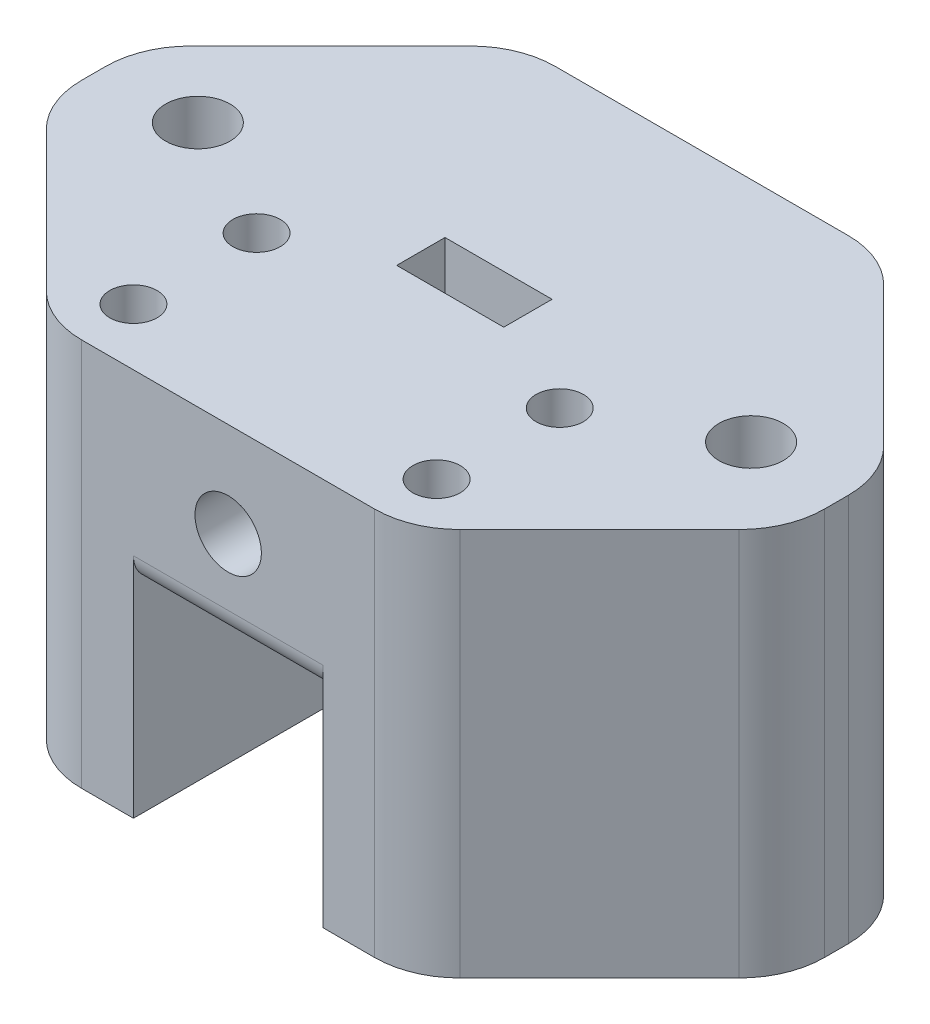
from build123d import *

# Parameters (mm, degrees)
SKETCH1_W                      = 39.2
SKETCH1_H                      = 25
BOSS_EXTRUDE1_DEPTH            = 10
F_3_5_3_5_DIAMETER_HOLE1_D     = 3.5
SKETCH9_W                      = 14.6
SKETCH9_H                      = 25
BOSS_EXTRUDE2_DEPTH            = 10.5
SKETCH10_W                     = 5.65
SKETCH10_H                     = 2.55
CUT_EXTRUDE4_DEPTH             = 10
F_2_5_2_5_DIAMETER_HOLE1_D     = 2.5
F_2_5_2_5_DIAMETER_HOLE1_DEPTH = 7
F_2_5_2_5_DIAMETER_HOLE1_TIP   = 0.751075774
F_3_4_3_4_DIAMETER_HOLE1_D     = 3.4
CHAMFER1_SIZE                  = 10
FILLET5_R                      = 4.5
FILLET6_R                      = 1.5
F_3_4_3_4_DIAMETER_HOLE2_D     = 3.4
F_3_4_3_4_DIAMETER_HOLE2_DEPTH = 4
F_3_4_3_4_DIAMETER_HOLE2_TIP   = 1.021463052


with BuildPart() as part:
    # Sketch1 → Boss-Extrude1 (new body)
    with BuildSketch(Plane(origin=(0, 0, 0), x_dir=(1, 0, 0), z_dir=(0, 1, 0))):
        with Locations((19.6, 12.5)):
            Rectangle(SKETCH1_W, SKETCH1_H)
    extrude(amount=BOSS_EXTRUDE1_DEPTH)

    # Ø3.5 (3.5) Diameter Hole1 (through all)
    with Locations(Plane(origin=(0, 0, -25), x_dir=(-1, 0, 0), z_dir=(0, 0, -1))):
        with Locations((-19.6, 5)):
            Hole(F_3_5_3_5_DIAMETER_HOLE1_D / 2)

    # Sketch9 → Boss-Extrude2 (add)
    with BuildSketch(Plane.XZ):
        with Locations((31.9, -12.5)):
            Rectangle(SKETCH9_W, SKETCH9_H)
        with Locations((7.3, -12.5)):
            Rectangle(SKETCH9_W, SKETCH9_H)
    extrude(amount=BOSS_EXTRUDE2_DEPTH)

    # Sketch10 → Cut-Extrude4 (cut)
    with BuildSketch(Plane(origin=(0, 10, 0), x_dir=(1, 0, 0), z_dir=(0, 1, 0))):
        with Locations((19.6, 12.995)):
            Rectangle(SKETCH10_W, SKETCH10_H)
    extrude(amount=-CUT_EXTRUDE4_DEPTH, mode=Mode.SUBTRACT)

    # Ø2.5 (2.5) Diameter Hole1
    with Locations(Plane(origin=(0, 10, 0), x_dir=(1, 0, 0), z_dir=(0, 1, 0))):
        with Locations((11.6, 3), (27.6, 3), (27.6, 9.5), (11.6, 9.5)):
            Hole(F_2_5_2_5_DIAMETER_HOLE1_D / 2, depth=F_2_5_2_5_DIAMETER_HOLE1_DEPTH)
            with Locations((0, 0, -(F_2_5_2_5_DIAMETER_HOLE1_DEPTH + F_2_5_2_5_DIAMETER_HOLE1_TIP / 2))):  # 118° drill point
                Cone(0, F_2_5_2_5_DIAMETER_HOLE1_D / 2, F_2_5_2_5_DIAMETER_HOLE1_TIP, mode=Mode.SUBTRACT)

    # Ø3.4 (3.4) Diameter Hole1 (through all)
    with Locations(Plane(origin=(0, 10, 0), x_dir=(1, 0, 0), z_dir=(0, 1, 0))):
        with Locations((34.2, 13), (5, 13)):
            Hole(F_3_4_3_4_DIAMETER_HOLE1_D / 2)

    # Chamfer1
    chamfer1_edges = [part.edges().sort_by_distance(p)[0] for p in [
        (0, -0.25, 0),
        (0, -0.25, -25),
        (39.2, -0.25, -25),
        (39.2, -0.25, 0),
    ]]
    chamfer(chamfer1_edges, length=CHAMFER1_SIZE)

    # Fillet5
    fillet5_edges = [part.edges().sort_by_distance(p)[0] for p in [
        (39.2, -0.25, -10),
        (0, -0.25, -10),
        (0, -0.25, -15),
        (29.2, -0.25, -25),
        (10, -0.25, -25),
        (29.2, -0.25, 0),
        (10, -0.25, 0),
        (39.2, -0.25, -15),
    ]]
    fillet(fillet5_edges, radius=FILLET5_R)

    # Fillet6
    fillet6_edges = [part.edges().sort_by_distance(p)[0] for p in [
        (19.6, 0, 0),
    ]]
    fillet(fillet6_edges, radius=FILLET6_R)

    # Ø3.4 (3.4) Diameter Hole2
    with Locations(Plane(origin=(0, -10.5, 0), x_dir=(-1, 0, 0), z_dir=(0, -1, 0))):
        with Locations((-9.6, 13), (-29.6, 13)):
            Hole(F_3_4_3_4_DIAMETER_HOLE2_D / 2, depth=F_3_4_3_4_DIAMETER_HOLE2_DEPTH)
            with Locations((0, 0, -(F_3_4_3_4_DIAMETER_HOLE2_DEPTH + F_3_4_3_4_DIAMETER_HOLE2_TIP / 2))):  # 118° drill point
                Cone(0, F_3_4_3_4_DIAMETER_HOLE2_D / 2, F_3_4_3_4_DIAMETER_HOLE2_TIP, mode=Mode.SUBTRACT)


solid = part.part
